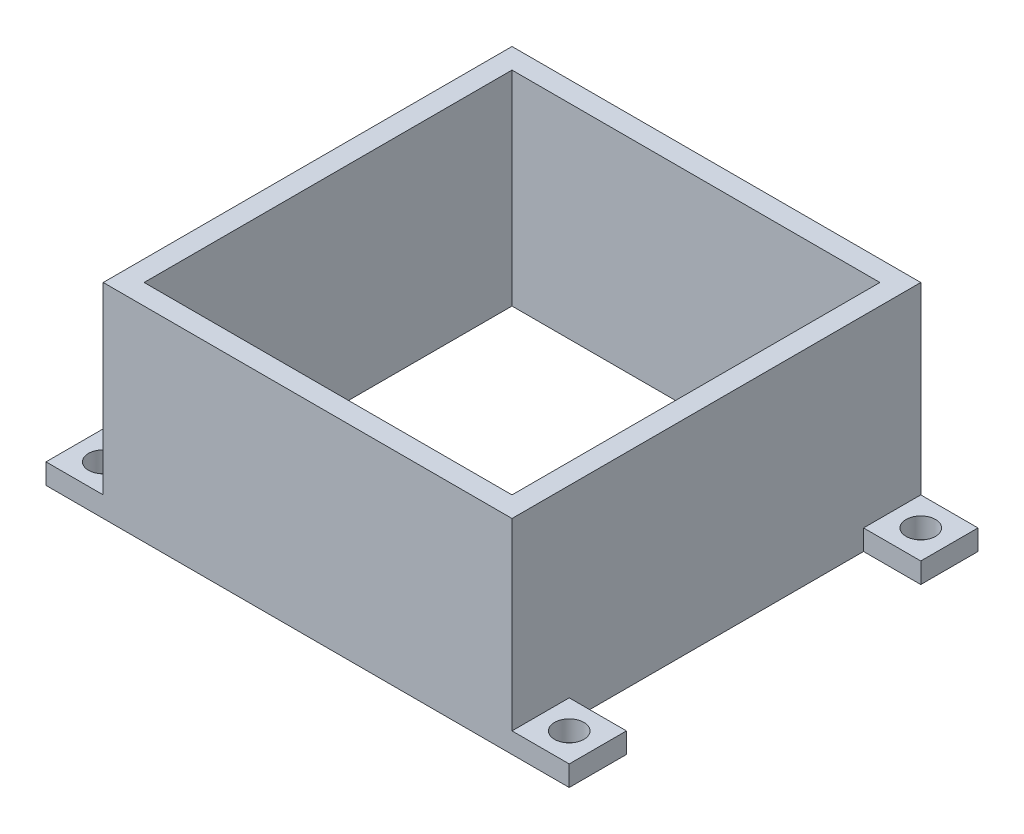
from build123d import *

# Parameters (mm, degrees)
SKIZZE1_W                       = 50
SKIZZE1_H                       = 50
SKIZZE1_W_2                     = 45
SKIZZE1_H_2                     = 45
AUFSATZ_LINEAR_AUSTRAGEN1_DEPTH = 25
SKIZZE2_W                       = 7
SKIZZE2_H                       = 7
SKIZZE2_R                       = 1.8
AUFSATZ_LINEAR_AUSTRAGEN2_DEPTH = 2.5
SPIEGELN2_COPY_1_SKETCH_W       = 7
SPIEGELN2_COPY_1_SKETCH_H       = 7
SPIEGELN2_COPY_1_SKETCH_R       = 1.8
SPIEGELN2_COPY_1_DEPTH          = 2.5


with BuildPart() as part:
    # Skizze1 → Aufsatz-Linear austragen1 (new body)
    with BuildSketch(Plane(origin=(0, 0, 0), x_dir=(1, 0, 0), z_dir=(0, 1, 0))):
        Rectangle(SKIZZE1_W, SKIZZE1_H)
        Rectangle(SKIZZE1_W_2, SKIZZE1_H_2, mode=Mode.SUBTRACT)
    extrude(amount=AUFSATZ_LINEAR_AUSTRAGEN1_DEPTH)

    # Skizze2 → Aufsatz-Linear austragen2 (add)
    with BuildSketch(Plane.XZ):
        with Locations((-28.5, 21.5)):
            Rectangle(SKIZZE2_W, SKIZZE2_H)
        with Locations((-28.5, 21.5)):
            Circle(SKIZZE2_R, mode=Mode.SUBTRACT)
    aufsatz_linear_austragen2 = extrude(amount=-AUFSATZ_LINEAR_AUSTRAGEN2_DEPTH)

    # Spiegeln1: Aufsatz-Linear austragen2 across plane
    add(aufsatz_linear_austragen2.mirror(Plane(origin=(0, 0, 0), x_dir=(0, 0, 1), z_dir=(1, 0, 0))))

    # Spiegeln2: Aufsatz-Linear austragen2 across plane
    add(aufsatz_linear_austragen2.mirror(Plane.XY))

    # Spiegeln2 copy 1 sketch → Spiegeln2 copy 1 (add)
    with BuildSketch(Plane(origin=(0, 0, 0), x_dir=(-1, 0, 0), z_dir=(0, -1, 0))):
        with Locations((-28.5, 21.5)):
            Rectangle(SPIEGELN2_COPY_1_SKETCH_W, SPIEGELN2_COPY_1_SKETCH_H)
        with Locations((-28.5, 21.5)):
            Circle(SPIEGELN2_COPY_1_SKETCH_R, mode=Mode.SUBTRACT)
    extrude(amount=-SPIEGELN2_COPY_1_DEPTH)


solid = part.part
